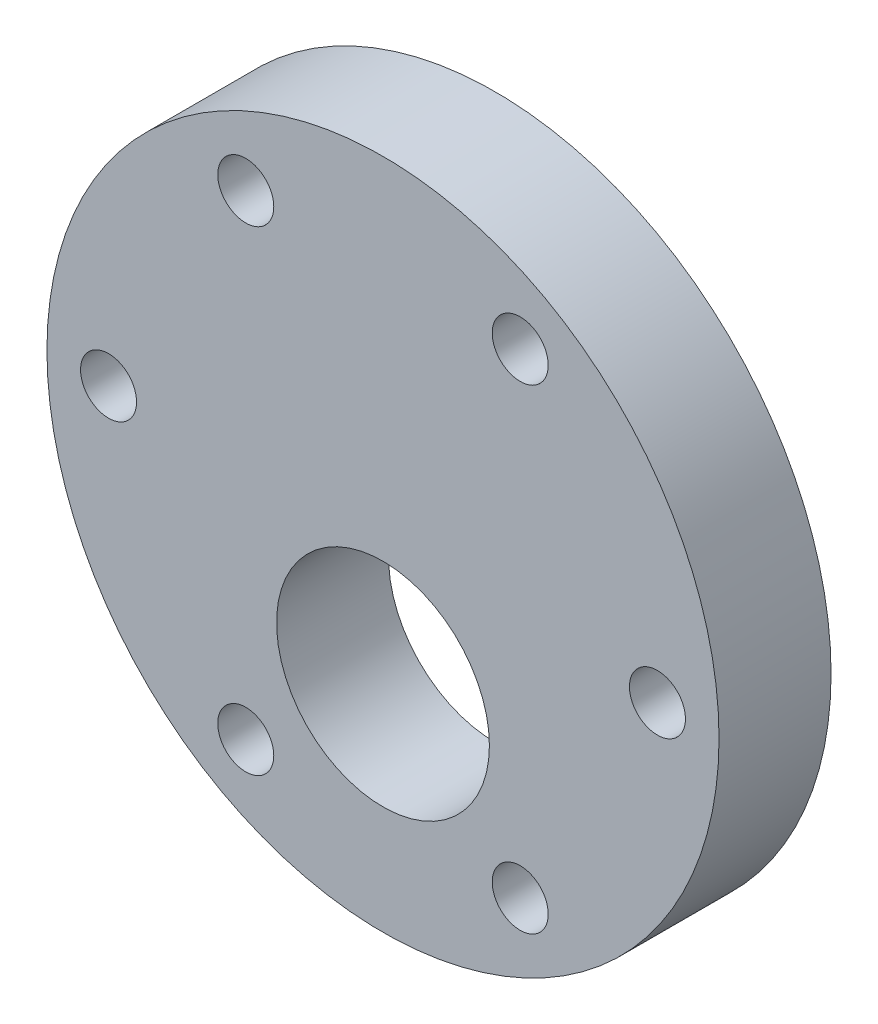
from build123d import *

# Parameters (mm, degrees)
SKETCH1_R           = 19.05
SKETCH1_R_2         = 6.0325
SKETCH1_R_3         = 1.5875
BOSS_EXTRUDE1_DEPTH = 6.35


with BuildPart() as part:
    # Sketch1 → Boss-Extrude1 (new body)
    with BuildSketch(Plane.XY):
        Circle(SKETCH1_R)
        with Locations((0, -6.858)):
            Circle(SKETCH1_R_2, mode=Mode.SUBTRACT)
        with Locations((-7.77875, 13.473190219)):
            Circle(SKETCH1_R_3, mode=Mode.SUBTRACT)
        with Locations((7.77875, 13.473190219)):
            Circle(SKETCH1_R_3, mode=Mode.SUBTRACT)
        with Locations((15.5575, 0)):
            Circle(SKETCH1_R_3, mode=Mode.SUBTRACT)
        with Locations((7.77875, -13.473190219)):
            Circle(SKETCH1_R_3, mode=Mode.SUBTRACT)
        with Locations((-7.77875, -13.473190219)):
            Circle(SKETCH1_R_3, mode=Mode.SUBTRACT)
        with Locations((-15.5575, 0)):
            Circle(SKETCH1_R_3, mode=Mode.SUBTRACT)
    extrude(amount=BOSS_EXTRUDE1_DEPTH)


solid = part.part
